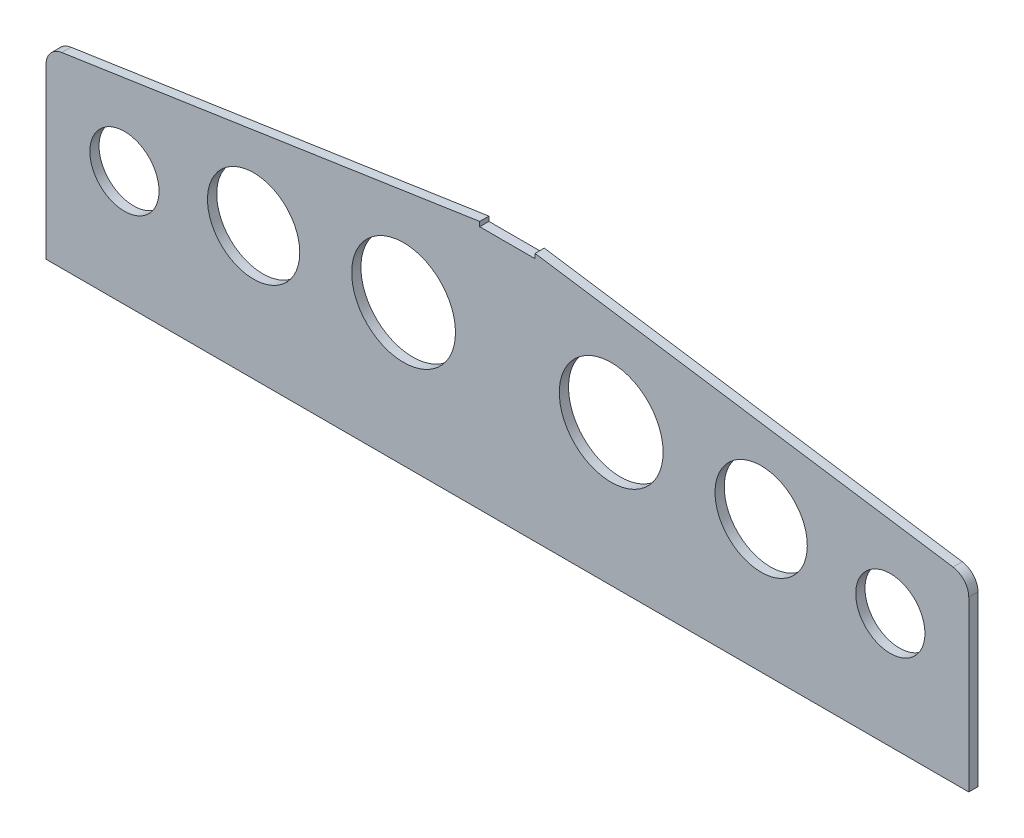
from build123d import *

# Parameters (mm, degrees)
SKETCH_1_R      = 15
SKETCH_1_R_2    = 20
SKETCH_1_R_3    = 22.5
EXTRUDE_1_DEPTH = 4


with BuildPart() as part:
    # 草图1 → 凸台-拉伸1 (new body)
    with BuildSketch(Plane.XY):
        with BuildLine():
            Line((-315.638914213, 504.066678813), (-315.638914213, 430.95617818))
            Line((-315.638914213, 430.95617818), (84.361085787, 430.95617818))
            Line((84.361085787, 430.95617818), (84.361085787, 504.066678813))
            ThreePointArc((84.361085787, 504.066678813), (82.42300747, 509.287129513), (77.547809411, 511.978169636))
            Line((77.547809411, 511.978169636), (-103.638914213, 539.15617818))
            Line((-103.638914213, 539.15617818), (-103.638914213, 537.15617818))
            Line((-103.638914213, 537.15617818), (-127.638914213, 537.15617818))
            Line((-127.638914213, 537.15617818), (-127.638914213, 539.15617818))
            Line((-127.638914213, 539.15617818), (-308.825637836, 511.978169636))
            ThreePointArc((-308.825637836, 511.978169636), (-313.700835896, 509.287129513), (-315.638914213, 504.066678813))
        make_face()
        with Locations((50.361085787, 480.95617818)):
            Circle(SKETCH_1_R, mode=Mode.SUBTRACT)
        with Locations((-5.638914213, 488.45617818)):
            Circle(SKETCH_1_R_2, mode=Mode.SUBTRACT)
        with Locations((-70.638914213, 492.20617818)):
            Circle(SKETCH_1_R_3, mode=Mode.SUBTRACT)
        with Locations((-281.638914213, 480.95617818)):
            Circle(SKETCH_1_R, mode=Mode.SUBTRACT)
        with Locations((-225.638914213, 488.45617818)):
            Circle(SKETCH_1_R_2, mode=Mode.SUBTRACT)
        with Locations((-160.638914213, 492.20617818)):
            Circle(SKETCH_1_R_3, mode=Mode.SUBTRACT)
    extrude(amount=EXTRUDE_1_DEPTH)


solid = part.part
